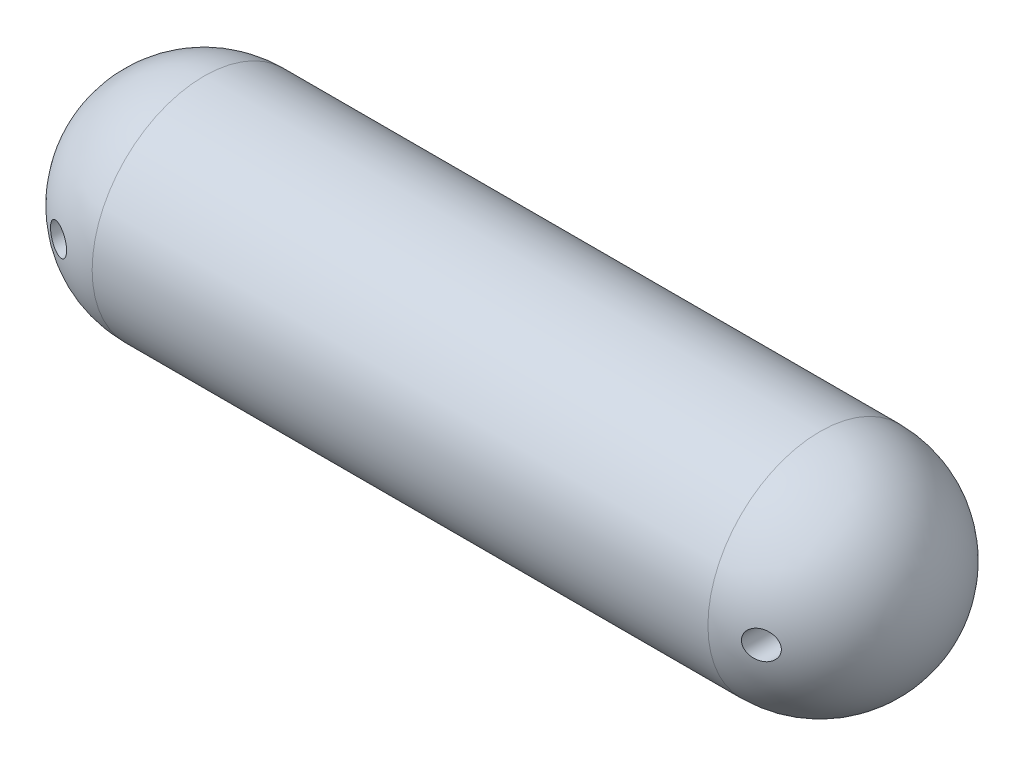
from build123d import *

# Parameters (mm, degrees)
CROQUIS6_R                 = 2.5
CORTAR_EXTRUIR1_DEPTH      = 21
CORTAR_EXTRUIR1_DEPTH_BACK = 21


with BuildPart() as part:
    # Croquis3 → Revolución10 (revolve)
    with BuildSketch(Plane(origin=(0, 0, 0), x_dir=(1, 0, 0), z_dir=(0, 1, 0))):
        with BuildLine():
            Line((17.080745342, 20), (107.080745342, 20))
            Line((107.080745342, 20), (127.080745342, 20))
            ThreePointArc((127.080745342, 20), (141.222880965, 14.142135624), (147.080745342, 0))
            Line((147.080745342, 0), (-2.919254658, 0))
            ThreePointArc((-2.919254658, 0), (2.938609718, 14.142135624), (17.080745342, 20))
        make_face()
    revolve(axis=Axis((-63.085280919, 0, 0), (1, 0, 0)))

    # Croquis6 → Cortar-Extruir1 (cut, two sides)
    with BuildSketch(Plane.XY) as cortar_extruir1_sk:
        with Locations((9.30480946, 0)):
            Circle(CROQUIS6_R)
        with Locations((134.856681223, 0)):
            Circle(CROQUIS6_R)
    extrude(amount=CORTAR_EXTRUIR1_DEPTH, mode=Mode.SUBTRACT)
    extrude(cortar_extruir1_sk.sketch, amount=-CORTAR_EXTRUIR1_DEPTH_BACK, mode=Mode.SUBTRACT)


solid = part.part
